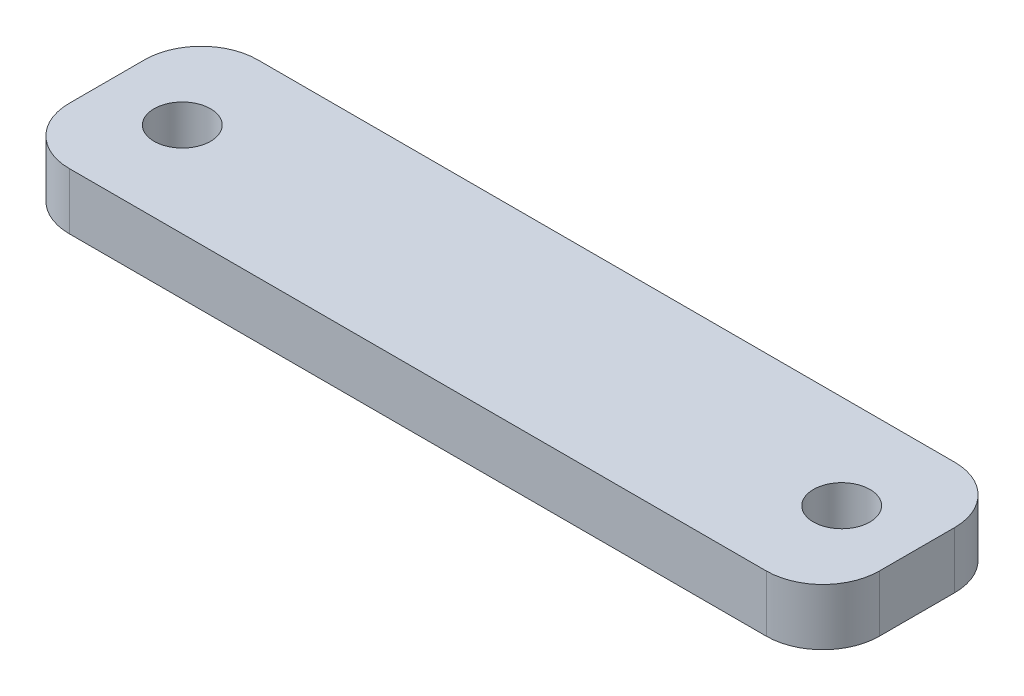
from build123d import *

# Parameters (mm, degrees)
SKETCH1_W             = 43
SKETCH1_H             = 10
BOSS_EXTRUDE1_DEPTH   = 3
FILLET1_R             = 3
F_3_0MM_DOWEL_HOLE1_D = 3


with BuildPart() as part:
    # Sketch1 → Boss-Extrude1 (new body)
    with BuildSketch(Plane(origin=(0, 0, 0), x_dir=(1, 0, 0), z_dir=(0, 1, 0))):
        Rectangle(SKETCH1_W, SKETCH1_H)
    extrude(amount=BOSS_EXTRUDE1_DEPTH)

    # Fillet1
    fillet1_edges = [part.edges().sort_by_distance(p)[0] for p in [
        (21.5, 1.5, 5),
        (-21.5, 1.5, 5),
        (-21.5, 1.5, -5),
        (21.5, 1.5, -5),
    ]]
    fillet(fillet1_edges, radius=FILLET1_R)

    # Ø3.0mm Dowel Hole1 (through all)
    with Locations(Plane(origin=(0, 0, 0), x_dir=(-1, 0, 0), z_dir=(0, -1, 0))):
        with Locations((-17.5, 0), (17.5, 0)):
            Hole(F_3_0MM_DOWEL_HOLE1_D / 2)


solid = part.part
